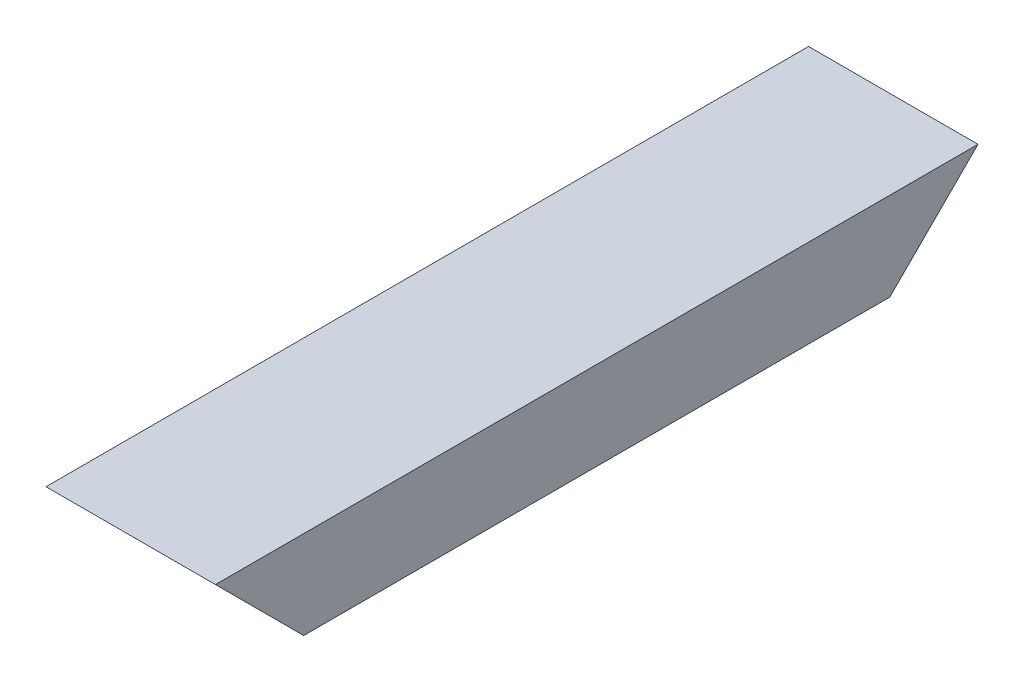
from build123d import *

# Parameters (mm, degrees)
BOSS_EXTRU_1_DEPTH      = 216
ENL_V_MAT_EXTRU_1_DEPTH = 49


with BuildPart() as part:
    # Esquisse1 → Boss.-Extru.1 (new body)
    with BuildSketch(Plane.XY):
        Polygon((105.75, 119), (105.75, 94), (80.75, 94), (80.75, 102), (57.75, 102), (57.75, 119), align=None)
    extrude(amount=BOSS_EXTRU_1_DEPTH)

    # Esquisse3 → Enlèv. mat.-Extru.1 (cut, through all)
    with BuildSketch(Plane(origin=(105.75, 0, 0), x_dir=(0, 0, -1), z_dir=(1, 0, 0))):
        Polygon((0, 119), (-25, 94), (0, 94), align=None)
        Polygon((-191, 94), (-216, 94), (-216, 119), align=None)
    extrude(amount=-ENL_V_MAT_EXTRU_1_DEPTH, mode=Mode.SUBTRACT)


solid = part.part
